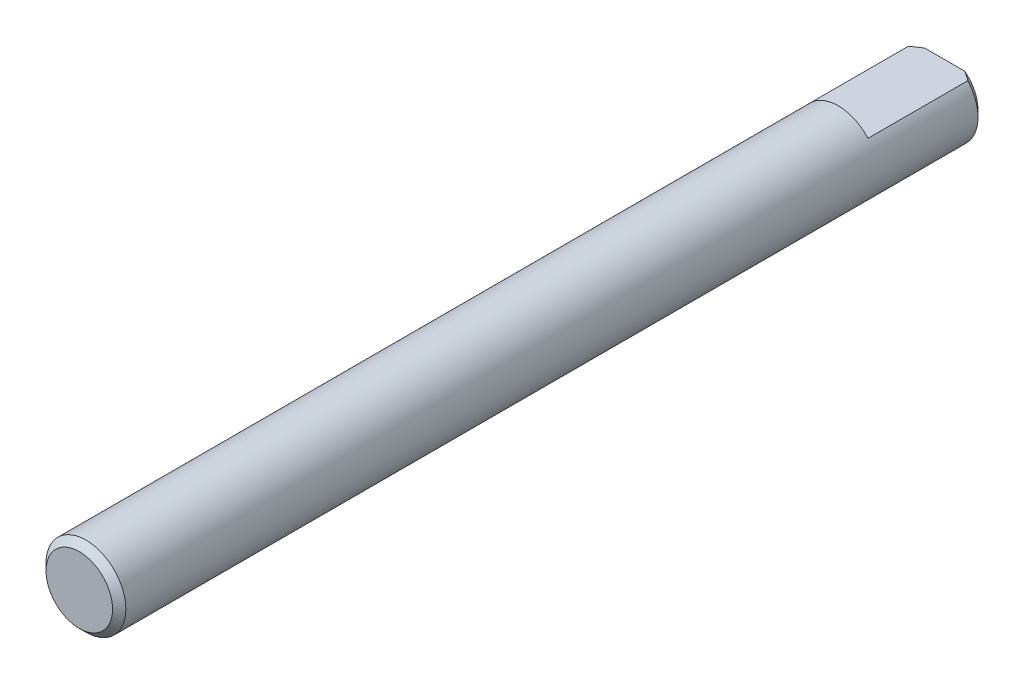
from build123d import *

# Parameters (mm, degrees)
SKETCH1_R           = 3
BOSS_EXTRUDE1_DEPTH = 32.5
CUT_EXTRUDE1_DEPTH  = 8
CHAMFER1_SIZE       = 0.5


with BuildPart() as part:
    # Sketch1 → Boss-Extrude1 (new body, symmetric)
    with BuildSketch(Plane.XY):
        Circle(SKETCH1_R)
    extrude(amount=BOSS_EXTRUDE1_DEPTH, both=True)

    # Sketch2 → Cut-Extrude1 (cut)
    with BuildSketch(Plane(origin=(0, 0, -32.5), x_dir=(-1, 0, 0), z_dir=(0, 0, -1))):
        with BuildLine():
            Line((-2.236067977, 2), (2.236067977, 2))
            ThreePointArc((2.236067977, 2), (0, 3), (-2.236067977, 2))
        make_face()
    extrude(amount=-CUT_EXTRUDE1_DEPTH, mode=Mode.SUBTRACT)

    # Chamfer1
    chamfer1_edges = [part.edges().sort_by_distance(p)[0] for p in [
        (-3, 0, 32.5),
        (-1.070466269, -2.802517077, -32.5),
    ]]
    chamfer(chamfer1_edges, length=CHAMFER1_SIZE)


solid = part.part
